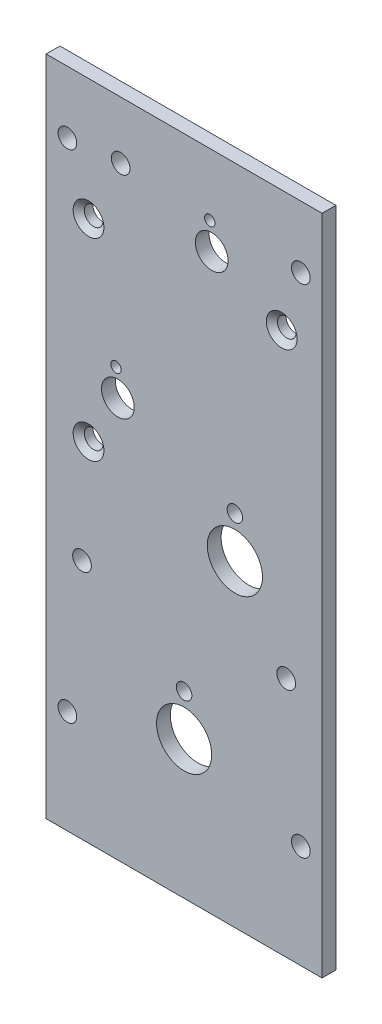
from build123d import *

# Parameters (mm, degrees)
SKETCH1_W                                         = 63.5
SKETCH1_H                                         = 152.4
BOSS_EXTRUDE1_DEPTH                               = 3.175
F_6_CLEARANCE_HOLE1_D                             = 4.3053
F_6_CLEARANCE_HOLE1_DEPTH                         = 3.175
F_6_CLEARANCE_HOLE2_D                             = 4.3053
F_6_CLEARANCE_HOLE2_DEPTH                         = 3.175
F_1_2_0_5_DIAMETER_HOLE1_D                        = 12.7
F_1_2_0_5_DIAMETER_HOLE1_DEPTH                    = 3.175
F_9_64_0_14063_DIAMETER_HOLE1_D                   = 3.572002
F_9_64_0_14063_DIAMETER_HOLE1_DEPTH               = 3.175
F_19_64_0_29688_DIAMETER_HOLE1_D                  = 7.540752
F_19_64_0_29688_DIAMETER_HOLE1_DEPTH              = 3.175
CSK_FOR_6_FLAT_HEAD_MACHINE_SCREW_100_D           = 4.3053
CSK_FOR_6_FLAT_HEAD_MACHINE_SCREW_100_DEPTH       = 3.175
CSK_FOR_6_FLAT_HEAD_MACHINE_SCREW_100_CSINK_D     = 7.0866
CSK_FOR_6_FLAT_HEAD_MACHINE_SCREW_100_CSINK_ANGLE = 100
F_3_32_0_09375_DIAMETER_HOLE1_D                   = 2.38125
F_3_32_0_09375_DIAMETER_HOLE1_DEPTH               = 3.175


with BuildPart() as part:
    # Sketch1 → Boss-Extrude1 (new body)
    with BuildSketch(Plane.XY):
        with Locations((0, -76.2)):
            Rectangle(SKETCH1_W, SKETCH1_H)
    extrude(amount=-BOSS_EXTRUDE1_DEPTH)

    # #6 Clearance Hole1
    with Locations(Plane.XY):
        with Locations((-26.8605, -14.2875), (26.8605, -14.2875), (26.8605, -128.5875), (-26.8605, -128.5875)):
            Hole(F_6_CLEARANCE_HOLE1_D / 2, depth=F_6_CLEARANCE_HOLE1_DEPTH)

    # #6 Clearance Hole2
    with Locations(Plane.XY):
        with Locations((-23.495, -96.8375), (23.495, -96.8375), (-14.605, -13.208)):
            Hole(F_6_CLEARANCE_HOLE2_D / 2, depth=F_6_CLEARANCE_HOLE2_DEPTH)

    # 1/2 (0.5) Diameter Hole1
    with Locations(Plane.XY):
        with Locations((11.684, -79.375), (0, -120.65)):
            Hole(F_1_2_0_5_DIAMETER_HOLE1_D / 2, depth=F_1_2_0_5_DIAMETER_HOLE1_DEPTH)

    # 9/64 (0.14063) Diameter Hole1
    with Locations(Plane.XY):
        with Locations((0, -111.125), (11.684, -69.85)):
            Hole(F_9_64_0_14063_DIAMETER_HOLE1_D / 2, depth=F_9_64_0_14063_DIAMETER_HOLE1_DEPTH)

    # 19/64 (0.29688) Diameter Hole1
    with Locations(Plane.XY):
        with Locations((-15.24, -60.325), (6.35, -20.32)):
            Hole(F_19_64_0_29688_DIAMETER_HOLE1_D / 2, depth=F_19_64_0_29688_DIAMETER_HOLE1_DEPTH)

    # CSK for #6 Flat Head Machine Screw (100)1
    with Locations(Plane.XY):
        with Locations((-21.99, -72.39), (-21.99, -27.94), (22.46, -27.94)):
            CounterSinkHole(CSK_FOR_6_FLAT_HEAD_MACHINE_SCREW_100_D / 2, CSK_FOR_6_FLAT_HEAD_MACHINE_SCREW_100_CSINK_D / 2, depth=CSK_FOR_6_FLAT_HEAD_MACHINE_SCREW_100_DEPTH, counter_sink_angle=CSK_FOR_6_FLAT_HEAD_MACHINE_SCREW_100_CSINK_ANGLE)

    # 3/32 (0.09375) Diameter Hole1
    with Locations(Plane.XY):
        with Locations((-15.688380535, -54.341777215), (5.901619465, -14.336777215)):
            Hole(F_3_32_0_09375_DIAMETER_HOLE1_D / 2, depth=F_3_32_0_09375_DIAMETER_HOLE1_DEPTH)


solid = part.part
